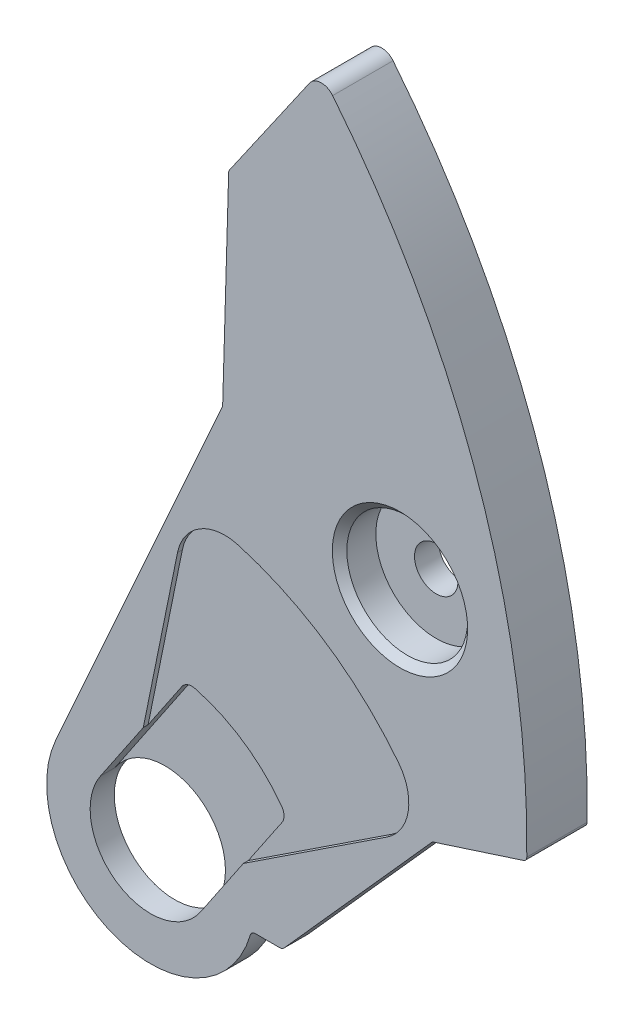
from build123d import *

# Parameters (mm, degrees)
BOSS_EXTRUDE1_DEPTH = 0.75
BOSS_EXTRUDE2_DEPTH = 0.5
CUT_EXTRUDE1_DEPTH  = 0.1
CUT_EXTRUDE2_DEPTH  = 0.2
SKETCH5_W           = 0.45
SKETCH5_H           = 0.6
SKETCH6_W           = 0.45
SKETCH6_H           = 0.6
SKETCH7_W           = 1.25
SKETCH7_H           = 0.5
HOLE1_D             = 0.9
HOLE1_DEPTH         = 1.85
HOLE1_CBORE_D       = 2.5
HOLE1_CBORE_DEPTH   = 0.75
FILLET1_R           = 0.1
CHAMFER1_SIZE       = 0.15
FILLET2_R           = 0.25
FILLET3_R           = 1


with BuildPart() as part:
    # Sketch1 → Boss-Extrude1 (new body)
    with BuildSketch(Plane(origin=(0, 0, 0), x_dir=(-1, 0, 0), z_dir=(0, 0, -1))):
        with BuildLine():
            Line((-18.147160188, -0.321056231), (-16.640459832, -0.807555039))
            ThreePointArc((-16.640459832, -0.807555039), (-14.376672703, 1.830313994), (-11.123104682, 3.053988922))
            Line((-11.123104682, 3.053988922), (-11.854774008, 4.687962623))
            Line((-11.854774008, 4.687962623), (-11.980143643, 8.966094329))
            Line((-11.980143643, 8.966094329), (-13.651153285, 11.372867219))
            ThreePointArc((-13.651153285, 11.372867219), (-13.886856414, 11.501581597), (-14.131154362, 11.390038472))
            ThreePointArc((-14.131154362, 11.390038472), (-17.168571063, 5.887500969), (-18.147160188, -0.321056231))
        make_face()
    extrude(amount=-BOSS_EXTRUDE1_DEPTH)

    # Sketch2 → Boss-Extrude2 (add)
    with BuildSketch(Plane.XY.offset(0.75)):
        with BuildLine():
            Line((18.147160188, -0.321056231), (16.196912485, -0.950772139))
            Line((16.196912485, -0.950772139), (13.090029226, -4.428012343))
            Line((13.090029226, -4.428012343), (12.448174494, -4.428012343))
            ThreePointArc((12.448174494, -4.428012343), (9.659124877, -5.936170482), (8.400603878, -3.02593619))
            Line((8.400603878, -3.02593619), (11.854774008, 4.687962623))
            Line((11.854774008, 4.687962623), (11.980143643, 8.966094329))
            Line((11.980143643, 8.966094329), (13.651153285, 11.372867219))
            ThreePointArc((13.651153285, 11.372867219), (13.886856414, 11.501581597), (14.131154362, 11.390038472))
            ThreePointArc((14.131154362, 11.390038472), (17.168571063, 5.887500969), (18.147160188, -0.321056231))
        make_face()
    extrude(amount=BOSS_EXTRUDE2_DEPTH)

    # Sketch3 → Cut-Extrude1 (cut)
    with BuildSketch(Plane.XY.offset(1.25)):
        with BuildLine():
            Line((11.118831997, 2.571420588), (10.212805559, -1.893755119))
            Line((10.212805559, -1.893755119), (9.327068413, -3.204862093))
            ThreePointArc((9.327068413, -3.204862093), (11.06260071, -2.868815002), (11.3986478, -4.604347299))
            Line((11.3986478, -4.604347299), (12.284384946, -3.293240325))
            Line((12.284384946, -3.293240325), (16.088661421, -0.786019055))
            ThreePointArc((16.088661421, -0.786019055), (14.012715525, 1.498074346), (11.118831997, 2.571420588))
        make_face()
    extrude(amount=-CUT_EXTRUDE1_DEPTH, mode=Mode.SUBTRACT)

    # Sketch4 → Cut-Extrude2 (cut)
    with BuildSketch(Plane.XY.offset(1.15)):
        with BuildLine():
            Line((11.006450661, -0.718966828), (9.327068413, -3.204862093))
            ThreePointArc((9.327068413, -3.204862093), (11.06260071, -2.868815002), (11.3986478, -4.604347299))
            Line((11.3986478, -4.604347299), (13.078030048, -2.118452035))
            ThreePointArc((13.078030048, -2.118452035), (12.182188875, -1.211551493), (11.006450661, -0.718966828))
        make_face()
    extrude(amount=-CUT_EXTRUDE2_DEPTH, mode=Mode.SUBTRACT)

    # Sketch5 → Revolve1 (revolve)
    with BuildSketch(Plane(origin=(0, 0.611982068, 0), x_dir=(1, 0, 0), z_dir=(0, 1, 0))):
        with Locations((17.216029708, 0.3)):
            Rectangle(SKETCH5_W, SKETCH5_H)
    revolve(axis=Axis((16.991029708, 0.611982068, -0.6), (0, 0, 1)))

    # Sketch6 → Revolve2 (revolve)
    with BuildSketch(Plane(origin=(0, 8.246041644, 0), x_dir=(1, 0, 0), z_dir=(0, 1, 0))):
        with Locations((14.535071469, 0.3)):
            Rectangle(SKETCH6_W, SKETCH6_H)
    revolve(axis=Axis((14.310071469, 8.246041644, -0.6), (0, 0, 1)))

    # Sketch7 → Cut-Revolve1 (revolve, cut)
    with BuildSketch(Plane.XZ.offset(3.904604696)):
        with Locations((10.987858107, 1)):
            Rectangle(SKETCH7_W, SKETCH7_H)
    revolve(axis=Axis((10.362858107, -3.904604696, 1.25), (0, 0, -1)), mode=Mode.SUBTRACT)

    # Hole1
    with Locations(Plane.XY.offset(1.25)):
        with Locations((15.524716589, 3.231351436)):
            CounterBoreHole(HOLE1_D / 2, HOLE1_CBORE_D / 2, HOLE1_CBORE_DEPTH, depth=HOLE1_DEPTH)

    # Fillet1
    fillet1_edges = [part.edges().sort_by_distance(p)[0] for p in [
        (13.860071469, 8.246041644, -0.6),
        (11.854774008, 4.687962623, 0.625),
        (12.448174494, -4.428012343, 1),
        (16.541029708, 0.611982068, -0.6),
        (11.980143643, 8.966094329, 0.625),
        (13.090029226, -4.428012343, 1),
        (18.147160188, -0.321056231, 0.625),
        (16.196912485, -0.950772139, 1),
    ]]
    fillet(fillet1_edges, radius=FILLET1_R)

    # Chamfer1
    chamfer1_edges = [part.edges().sort_by_distance(p)[0] for p in [
        (14.274716589, 3.231351436, 1.25),
    ]]
    chamfer(chamfer1_edges, length=CHAMFER1_SIZE)

    # Fillet2
    fillet2_edges = [part.edges().sort_by_distance(p)[0] for p in [
        (13.078030048, -2.118452035, 1.05),
        (11.006450661, -0.718966828, 1.05),
    ]]
    fillet(fillet2_edges, radius=FILLET2_R)

    # Fillet3
    fillet3_edges = [part.edges().sort_by_distance(p)[0] for p in [
        (11.118831997, 2.571420588, 1.2),
        (16.088661421, -0.786019055, 1.2),
    ]]
    fillet(fillet3_edges, radius=FILLET3_R)


solid = part.part
